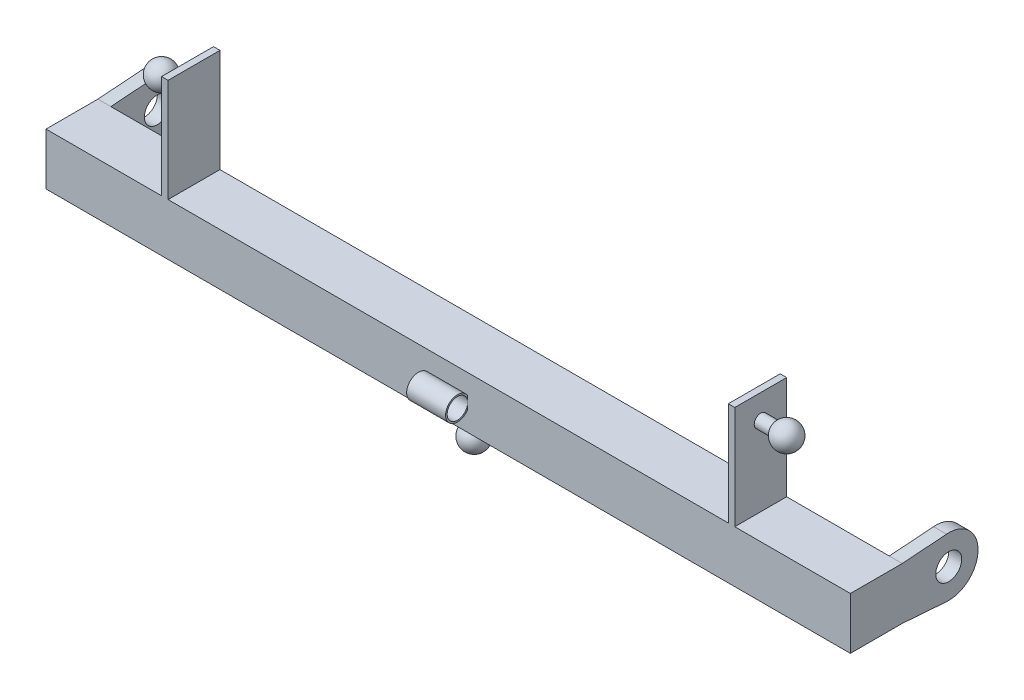
from build123d import *

# Parameters (mm, degrees)
SKETCH1_W           = 50.8
SKETCH1_H           = 50.8
SKETCH1_W_2         = 47.625
SKETCH1_H_2         = 47.625
BOSS_EXTRUDE1_DEPTH = 381
SKETCH2_R           = 11.598122223
SKETCH2_R_2         = 10.010622223
BOSS_EXTRUDE2_DEPTH = 19.05
SKETCH3_W           = 6.35
SKETCH3_H           = 50.8
BOSS_EXTRUDE3_DEPTH = 101.092
SKETCH7_R           = 12.7
BOSS_EXTRUDE4_DEPTH = 12.7


with BuildPart() as part:
    # Sketch1 → Boss-Extrude1 (new body, symmetric)
    with BuildSketch(Plane(origin=(0, 0, 0), x_dir=(0, 0, -1), z_dir=(1, 0, 0))):
        Rectangle(SKETCH1_W, SKETCH1_H)
        Rectangle(SKETCH1_W_2, SKETCH1_H_2, mode=Mode.SUBTRACT)
    extrude(amount=BOSS_EXTRUDE1_DEPTH, both=True)

    # Sketch2 → Boss-Extrude2 (add, symmetric)
    with BuildSketch(Plane(origin=(0, 0, 0), x_dir=(0, 0, -1), z_dir=(1, 0, 0))):
        with Locations((-35.410622223, 0)):
            Circle(SKETCH2_R)
        with Locations((-35.410622223, 0)):
            Circle(SKETCH2_R_2, mode=Mode.SUBTRACT)
    extrude(amount=BOSS_EXTRUDE2_DEPTH, both=True)

    # Sketch3 → Boss-Extrude3 (add)
    with BuildSketch(Plane(origin=(0, 25.4, 0), x_dir=(1, 0, 0), z_dir=(0, 1, 0))):
        with Locations((-277.368, 0)):
            Rectangle(SKETCH3_W, SKETCH3_H)
        with Locations((277.368, 0)):
            Rectangle(SKETCH3_W, SKETCH3_H)
    extrude(amount=BOSS_EXTRUDE3_DEPTH)

    # Sketch5 → Revolve1 (revolve)
    with BuildSketch(Plane.XY):
        with BuildLine():
            Line((280.543, 108.966), (294.944477372, 108.966))
            ThreePointArc((294.944477372, 108.966), (309.230001873, 114.883257994), (318.643, 102.616))
            Line((318.643, 102.616), (280.543, 102.616))
            Line((280.543, 102.616), (280.543, 108.966))
        make_face()
    revolve1 = revolve(axis=Axis((280.543, 102.616, 0), (1, 0, 0)))

    # Mirror1: Revolve1 across plane
    add(revolve1.mirror(Plane(origin=(0, 0, 0), x_dir=(0, 0, 1), z_dir=(1, 0, 0))))

    # Sketch6 → Revolve2 (revolve)
    with BuildSketch(Plane(origin=(0, 0, 0), x_dir=(0, 0, -1), z_dir=(1, 0, 0))):
        with BuildLine():
            Line((-6.35, -25.4), (0, -25.4))
            Line((0, -25.4), (0, -63.5))
            ThreePointArc((0, -63.5), (-12.267257994, -54.087001873), (-6.35, -39.801477372))
            Line((-6.35, -39.801477372), (-6.35, -25.4))
        make_face()
    revolve(axis=Axis((0, -25.4, 0), (0, -1, 0)))

    # Sketch7 → Boss-Extrude4 (add)
    with BuildSketch(Plane(origin=(381, 0, 0), x_dir=(0, 0, -1), z_dir=(1, 0, 0))):
        with BuildLine():
            Line((68.713128758, -28.652376301), (25.4, -25.4))
            Line((25.4, -25.4), (-25.4, -25.4))
            Line((-25.4, -25.4), (-25.4, 25.4))
            Line((-25.4, 25.4), (25.4, 25.4))
            Line((25.4, 25.4), (68.713128758, 28.6523763))
            ThreePointArc((68.713128758, 28.6523763), (99.597672127, 0), (68.713128758, -28.652376301))
        make_face()
        with Locations((70.86463137, 0)):
            Circle(SKETCH7_R, mode=Mode.SUBTRACT)
    boss_extrude4 = extrude(amount=BOSS_EXTRUDE4_DEPTH)

    # Mirror2: Boss-Extrude4 across plane
    add(boss_extrude4.mirror(Plane(origin=(0, 0, 0), x_dir=(0, 0, 1), z_dir=(1, 0, 0))))


solid = part.part
